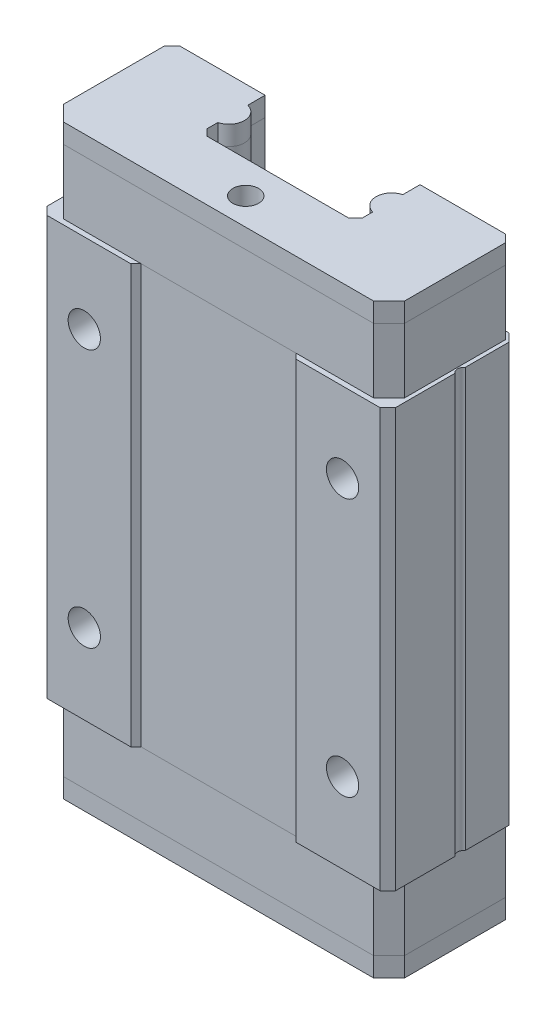
from build123d import *

# Parameters (mm, degrees)
SKICA1_W                 = 27
SKICA1_H                 = 32.4
P_IDAT_VYSUNUT_M1_DEPTH  = 10
ZKOSEN_1_SIZE            = 0.6
ODEBRAT_VYSUNUT_M1_DEPTH = 33.4
M3_Z_VIT1_D              = 2.5
M3_Z_VIT1_DEPTH          = 6
M3_Z_VIT1_TIP            = 0.751075774
P_IDAT_VYSUNUT_M2_DEPTH  = 5
P_IDAT_VYSUNUT_M3_DEPTH  = 1.5
LINPOLE1_COUNT           = 2
LINPOLE1_PITCH           = 37.4
LINPOLE2_COUNT           = 2
LINPOLE2_PITCH           = 43.9
ODEBRAT_VYSUNUT_M2_DEPTH = 46.4
ODEBRAT_VYSUNUT_M3_DEPTH = 39.9
SKICA9_R                 = 1
ODEBRAT_VYSUNUT_M4_DEPTH = 2


with BuildPart() as part:
    # Skica1 → Přidat vysunutím1 (new body)
    with BuildSketch(Plane.XY):
        Rectangle(SKICA1_W, SKICA1_H)
    extrude(amount=P_IDAT_VYSUNUT_M1_DEPTH)

    # Zkosení1
    zkosen_1_edges = [part.edges().sort_by_distance(p)[0] for p in [
        (-13.5, 0, 10),
        (13.5, 0, 10),
        (-13.5, 0, 0),
        (13.5, 0, 0),
    ]]
    chamfer(zkosen_1_edges, length=ZKOSEN_1_SIZE)

    # Skica2 → Odebrat vysunutím1 (cut, through all)
    with BuildSketch(Plane.XZ.offset(16.2)):
        Polygon((-6.4, 10), (6.400378165, 10), (6, 9.6), (-6, 9.6), align=None)
    extrude(amount=-ODEBRAT_VYSUNUT_M1_DEPTH, mode=Mode.SUBTRACT)

    # M3 závit1
    with Locations(Plane.XY.offset(10)):
        with Locations((-10, 10), (-10, -10), (10, -10), (10, 10)):
            Hole(M3_Z_VIT1_D / 2, depth=M3_Z_VIT1_DEPTH)
            with Locations((0, 0, -(M3_Z_VIT1_DEPTH + M3_Z_VIT1_TIP / 2))):  # 118° drill point
                Cone(0, M3_Z_VIT1_D / 2, M3_Z_VIT1_TIP, mode=Mode.SUBTRACT)


with BuildPart() as body_2:
    # Skica5 → Přidat vysunutím2 (new body)
    with BuildSketch(Plane.XZ.offset(16.2)):
        Polygon((-6, 9.6), (6, 9.6), (12, 9.6), (13.2, 8.4), (13.2, 0.6), (12.6, 0), (-12.6, 0), (-13.2, 0.6), (-13.2, 8.4), (-12, 9.6), align=None)
    p_idat_vysunut_m2 = extrude(amount=P_IDAT_VYSUNUT_M2_DEPTH)


with BuildPart() as body_3:
    # Skica6 → Přidat vysunutím3 (new body)
    with BuildSketch(Plane.XZ.offset(21.2)):
        Polygon((12, 9.6), (-12, 9.6), (-13.2, 8.4), (-13.2, 0.6), (-12.6, 0), (12.6, 0), (13.2, 0.6), (13.2, 8.4), align=None)
    extrude(amount=P_IDAT_VYSUNUT_M3_DEPTH)


with BuildPart() as linpole1_1:
    # LinPole1: Přidat vysunutím2 ×2
    with Locations(*[(0, i * LINPOLE1_PITCH, 0) for i in range(1, LINPOLE1_COUNT)]):
        add(p_idat_vysunut_m2)


with BuildPart() as linpole2_1:
    # LinPole2: pattern copy
    add(body_3.part.moved(Location(Vector(0, 1, 0) * (1 * LINPOLE2_PITCH))))


with BuildPart() as odebrat_vysunut_m2_tool:
    # Skica7 → Odebrat vysunutím2 (new body, through all)
    with BuildSketch(Plane.XZ.offset(22.7)):
        with BuildLine():
            Line((-6, 1.338104996), (-6, 0))
            Line((-6, 0), (6, 0))
            Line((6, 0), (6, 1.338104996))
            ThreePointArc((6, 1.338104996), (5.1, 2.5), (6, 3.661895004))
            Line((6, 3.661895004), (6, 4.5))
            Line((6, 4.5), (5.5, 5))
            Line((5.5, 5), (-5.5, 5))
            Line((-5.5, 5), (-6, 4.5))
            Line((-6, 4.5), (-6, 3.661895004))
            ThreePointArc((-6, 3.661895004), (-5.1, 2.5), (-6, 1.338104996))
        make_face()
    extrude(amount=-ODEBRAT_VYSUNUT_M2_DEPTH)


with BuildPart() as part_1:
    add(part.part)

    # Odebrat vysunutím2: cut by odebrat_vysunut_m2_tool
    add(odebrat_vysunut_m2_tool.part, mode=Mode.SUBTRACT)

    # Skica8 → Odebrat vysunutím3 (cut, through all)
    with BuildSketch(Plane.XZ.offset(16.2)):
        with BuildLine():
            Line((13.5, 4.8), (13.5, 4))
            ThreePointArc((13.5, 4), (13.3, 4.4), (13.5, 4.8))
        make_face()
    extrude(amount=-ODEBRAT_VYSUNUT_M3_DEPTH, mode=Mode.SUBTRACT)


with BuildPart() as body_2_1:
    add(body_2.part)

    # Odebrat vysunutím2: cut by odebrat_vysunut_m2_tool
    add(odebrat_vysunut_m2_tool.part, mode=Mode.SUBTRACT)


with BuildPart() as body_3_1:
    add(body_3.part)

    # Odebrat vysunutím2: cut by odebrat_vysunut_m2_tool
    add(odebrat_vysunut_m2_tool.part, mode=Mode.SUBTRACT)


with BuildPart() as linpole1_1_1:
    add(linpole1_1.part)

    # Odebrat vysunutím2: cut by odebrat_vysunut_m2_tool
    add(odebrat_vysunut_m2_tool.part, mode=Mode.SUBTRACT)


with BuildPart() as linpole2_1_1:
    add(linpole2_1.part)

    # Odebrat vysunutím2: cut by odebrat_vysunut_m2_tool
    add(odebrat_vysunut_m2_tool.part, mode=Mode.SUBTRACT)


with BuildPart() as odebrat_vysunut_m4_tool:
    # Skica9 → Odebrat vysunutím4 (new body)
    with BuildSketch(Plane(origin=(0, 22.7, 0), x_dir=(1, 0, 0), z_dir=(0, 1, 0))):
        with Locations((0, -7.5)):
            Circle(SKICA9_R)
    odebrat_vysunut_m4 = extrude(amount=-ODEBRAT_VYSUNUT_M4_DEPTH)


with BuildPart() as linpole1_1_2:
    add(linpole1_1_1.part)

    # Odebrat vysunutím4: cut by odebrat_vysunut_m4_tool
    add(odebrat_vysunut_m4_tool.part, mode=Mode.SUBTRACT)


with BuildPart() as linpole2_1_2:
    add(linpole2_1_1.part)

    # Odebrat vysunutím4: cut by odebrat_vysunut_m4_tool
    add(odebrat_vysunut_m4_tool.part, mode=Mode.SUBTRACT)


with BuildPart() as zrcadlit4_tool:
    # Zrcadlit4: Odebrat vysunutím4 across plane
    add(odebrat_vysunut_m4.mirror(Plane.ZX))


with BuildPart() as body_2_2:
    add(body_2_1.part)

    # Zrcadlit4: cut by zrcadlit4_tool
    add(zrcadlit4_tool.part, mode=Mode.SUBTRACT)


with BuildPart() as body_3_2:
    add(body_3_1.part)

    # Zrcadlit4: cut by zrcadlit4_tool
    add(zrcadlit4_tool.part, mode=Mode.SUBTRACT)


solid = Compound([part_1.part, linpole1_1_2.part, linpole2_1_2.part, body_2_2.part, body_3_2.part])
